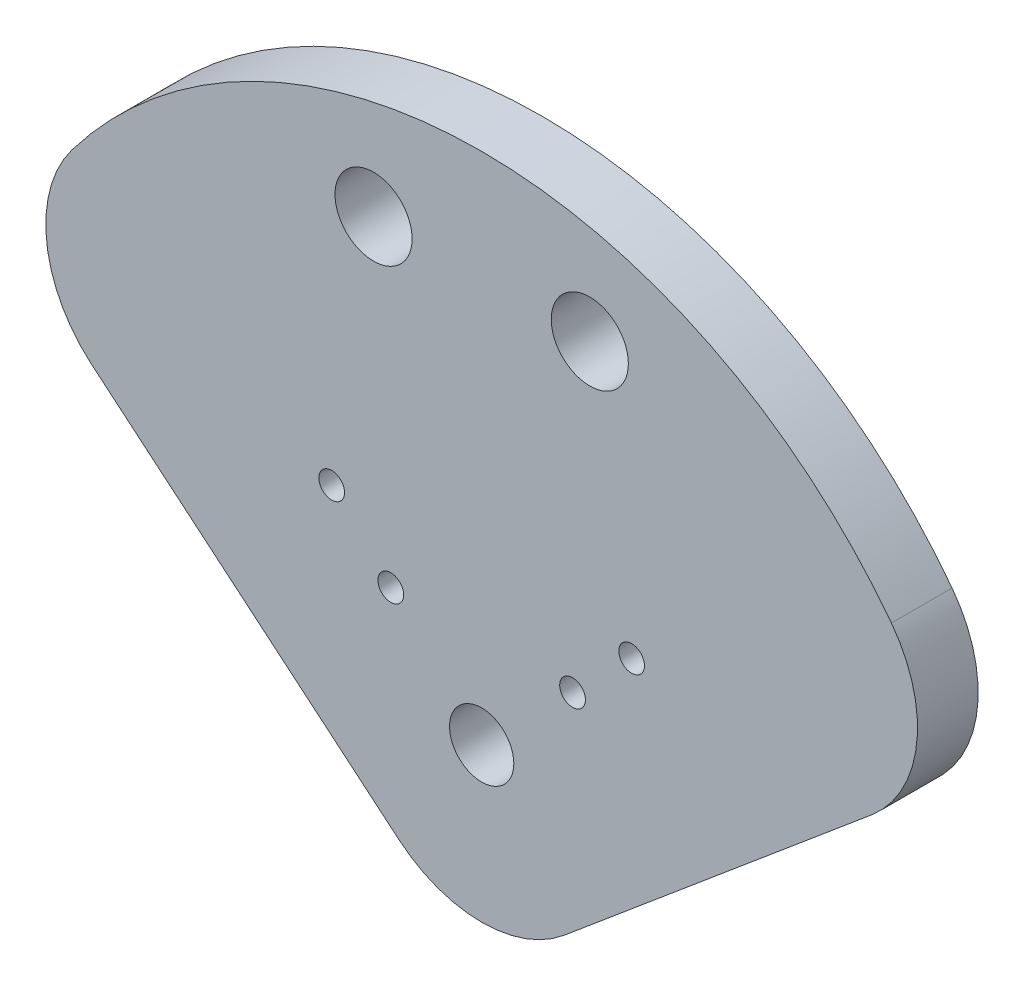
from build123d import *

# Parameters (mm, degrees)
SKETCH1_R           = 3.81
SKETCH1_R_2         = 1.27
SKETCH1_R_3         = 3.175
BOSS_EXTRUDE1_DEPTH = 5.9944
FILLET1_R           = 12.7
FILLET2_R           = 12.7


with BuildPart() as part:
    # Sketch1 → Boss-Extrude1 (new body)
    with BuildSketch(Plane.XY):
        with BuildLine():
            Line((-46.655107065, 20.09828313), (0, -19.05))
            Line((0, -19.05), (46.655107065, 20.09828313))
            ThreePointArc((46.655107065, 20.09828313), (0, 50.8), (-46.655107065, 20.09828313))
        make_face()
        with Locations((-10.682756087, 39.86858848)):
            Circle(SKETCH1_R, mode=Mode.SUBTRACT)
        with Locations((10.682756087, 39.86858848)):
            Circle(SKETCH1_R, mode=Mode.SUBTRACT)
        with Locations((-14.8174226, 14.8174226)):
            Circle(SKETCH1_R_2, mode=Mode.SUBTRACT)
        with Locations((-8.980256121, 8.980256121)):
            Circle(SKETCH1_R_2, mode=Mode.SUBTRACT)
        with Locations((8.980256121, 8.980256121)):
            Circle(SKETCH1_R_2, mode=Mode.SUBTRACT)
        with Locations((14.8174226, 14.8174226)):
            Circle(SKETCH1_R_2, mode=Mode.SUBTRACT)
        Circle(SKETCH1_R_3, mode=Mode.SUBTRACT)
    extrude(amount=BOSS_EXTRUDE1_DEPTH)

    # Fillet1
    fillet1_edges = [part.edges().sort_by_distance(p)[0] for p in [
        (46.655107065, 20.09828313, 2.9972),
        (-46.655107065, 20.09828313, 2.9972),
    ]]
    fillet(fillet1_edges, radius=FILLET1_R)

    # Fillet2
    fillet2_edges = [part.edges().sort_by_distance(p)[0] for p in [
        (0, -19.05, 2.9972),
    ]]
    fillet(fillet2_edges, radius=FILLET2_R)


solid = part.part
